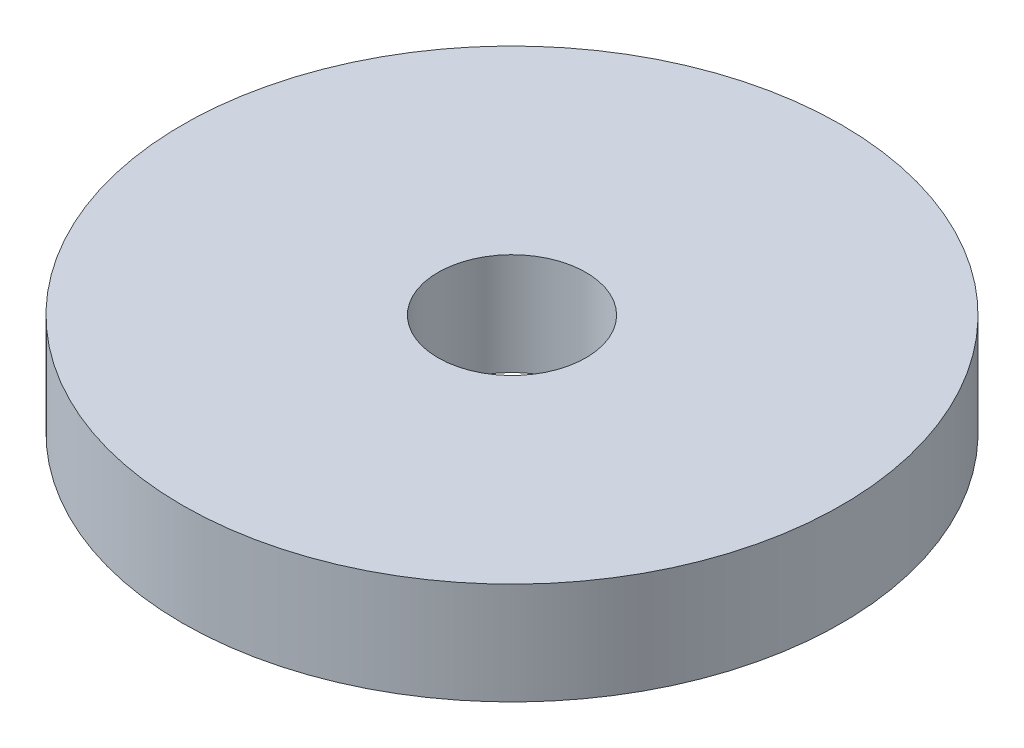
from build123d import *

# Parameters (mm, degrees)
SKETCH1_R           = 22.97040039
SKETCH1_R_2         = 5.157338114
BOSS_EXTRUDE1_DEPTH = 7.112


with BuildPart() as part:
    # Sketch1 → Boss-Extrude1 (new body)
    with BuildSketch(Plane(origin=(0, 0, 0), x_dir=(1, 0, 0), z_dir=(0, 1, 0))):
        Circle(SKETCH1_R)
        Circle(SKETCH1_R_2, mode=Mode.SUBTRACT)
    extrude(amount=BOSS_EXTRUDE1_DEPTH)


solid = part.part
